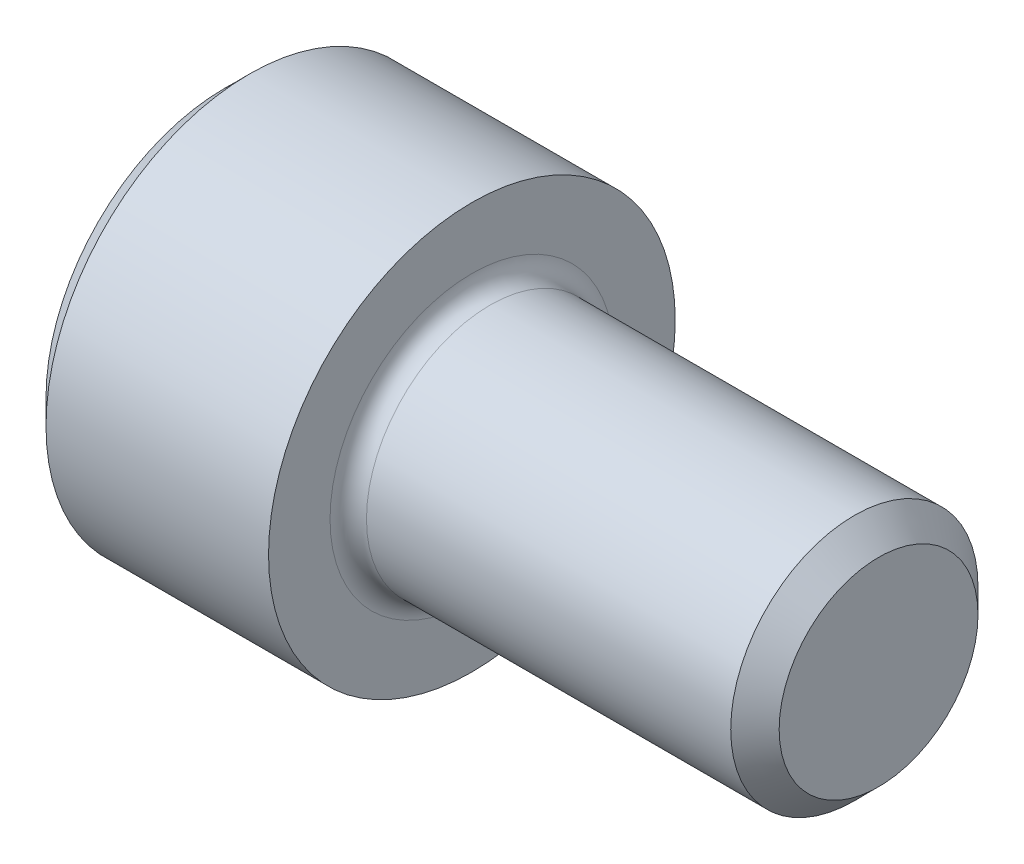
from build123d import *

# Parameters (mm, degrees)
FILLET1_R   = 0.3556
HEX_2_DEPTH = 2.286


with BuildPart() as part:
    # BodySke → Base-Revolve (revolve)
    with BuildSketch(Plane.XY):
        Polygon((0, 0), (0, 3.48615), (0.4826, 3.96875), (4.826, 3.96875), (4.826, 2.413), (12.29106, 2.413), (12.7635, 1.94056), (12.7635, 0), align=None)
    revolve(axis=Axis((-31.75, 0, 0), (1, 0, 0)))

    # Fillet1
    fillet1_edges = [part.edges().sort_by_distance(p)[0] for p in [
        (4.826, -2.413, 0),
    ]]
    fillet(fillet1_edges, radius=FILLET1_R)

    # Sketch2 → Hex-PreBroach (revolve, cut)
    with BuildSketch(Plane.XY):
        Polygon((0, 1.98501), (2.286, 1.98501), (3.432046058, 0), (0, 0), align=None)
    revolve(axis=Axis((0, 0, 0), (1, 0, 0)), mode=Mode.SUBTRACT)

    # Sketch3 → Hex 2 (cut)
    with BuildSketch(Plane(origin=(0, 0, 0), x_dir=(0, 0.5, 0.866025404), z_dir=(-1, 0, 0))):
        Polygon((1.146046058, 1.98501), (-1.146046058, 1.98501), (-2.292092116, 0), (-1.146046058, -1.98501), (1.146046058, -1.98501), (2.292092116, 0), align=None)
    extrude(amount=-HEX_2_DEPTH, mode=Mode.SUBTRACT)


solid = part.part
